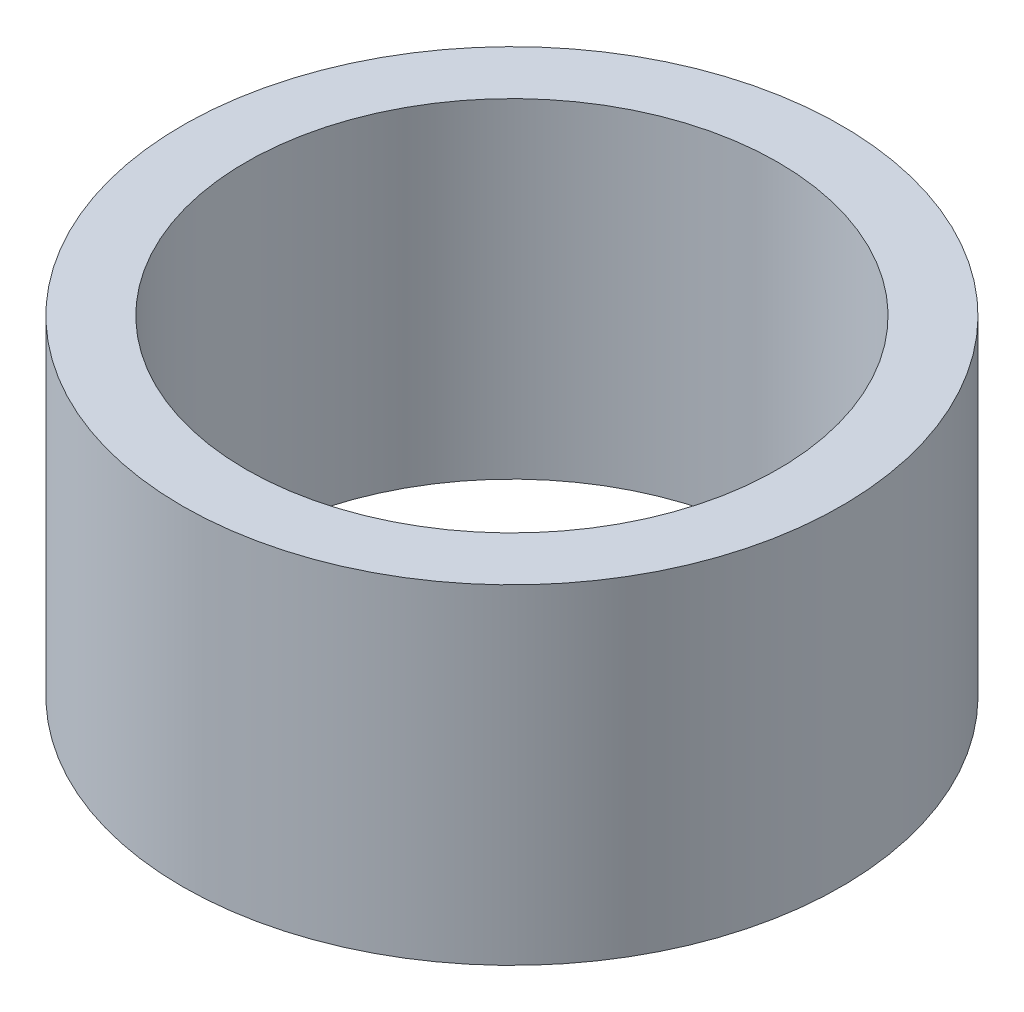
from build123d import *

# Parameters (mm, degrees)
SKETCH_1_W = 4.9
SKETCH_1_H = 25.4


with BuildPart() as part:
    # 草图1 → 旋转1 (revolve)
    with BuildSketch(Plane.XY, mode=Mode.PRIVATE) as revolve_1_sk:
        with Locations((22.95, 12.7)):
            Rectangle(SKETCH_1_W, SKETCH_1_H)
    revolve(revolve_1_sk.sketch.rotate(Axis((0, 161.376166943, 0), (0, -1, 0)), 90), axis=Axis((0, 161.376166943, 0), (0, -1, 0)))  # turned: the seam where the file's is


solid = part.part
